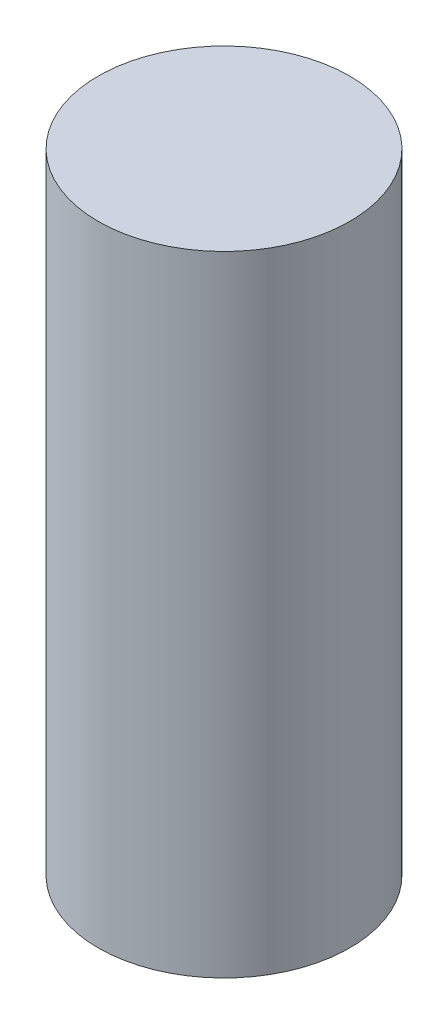
from build123d import *

# Parameters (mm, degrees)
SKETCH_1_R      = 5
EXTRUDE_1_DEPTH = 25


with BuildPart() as part:
    # 草图1 → 凸台-拉伸1 (new body)
    with BuildSketch(Plane(origin=(0, 0, 0), x_dir=(1, 0, 0), z_dir=(0, 1, 0))):
        Circle(SKETCH_1_R)
    extrude(amount=EXTRUDE_1_DEPTH)


solid = part.part
